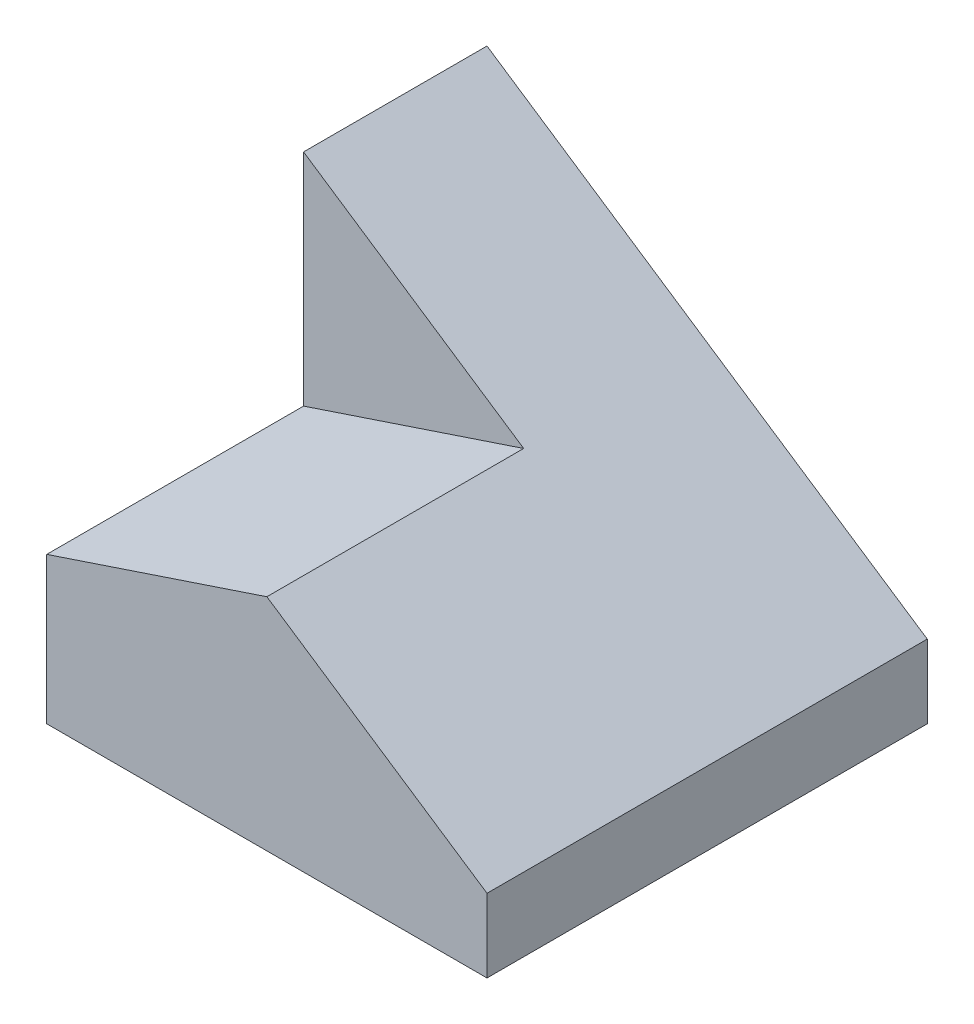
from build123d import *

# Parameters (mm, degrees)
SKETCH1_W           = 6
SKETCH1_H           = 6
BOSS_EXTRUDE1_DEPTH = 5
CUT_EXTRUDE7_DEPTH  = 8
CUT_EXTRUDE8_DEPTH  = 3.5


with BuildPart() as part:
    # Sketch1 → Boss-Extrude1 (new body)
    with BuildSketch(Plane(origin=(0, 0, 0), x_dir=(1, 0, 0), z_dir=(0, 1, 0))):
        Rectangle(SKETCH1_W, SKETCH1_H)
    extrude(amount=BOSS_EXTRUDE1_DEPTH)

    # Sketch10 → Cut-Extrude7 (cut)
    with BuildSketch(Plane.XY.offset(3)):
        Polygon((3, 5), (-3, 5), (3, 1), align=None)
    extrude(amount=-CUT_EXTRUDE7_DEPTH, mode=Mode.SUBTRACT)

    # Sketch11 → Cut-Extrude8 (cut)
    with BuildSketch(Plane.XY.offset(3)):
        Polygon((-3, 5), (-3, 2), (0, 3), align=None)
    extrude(amount=-CUT_EXTRUDE8_DEPTH, mode=Mode.SUBTRACT)


solid = part.part
